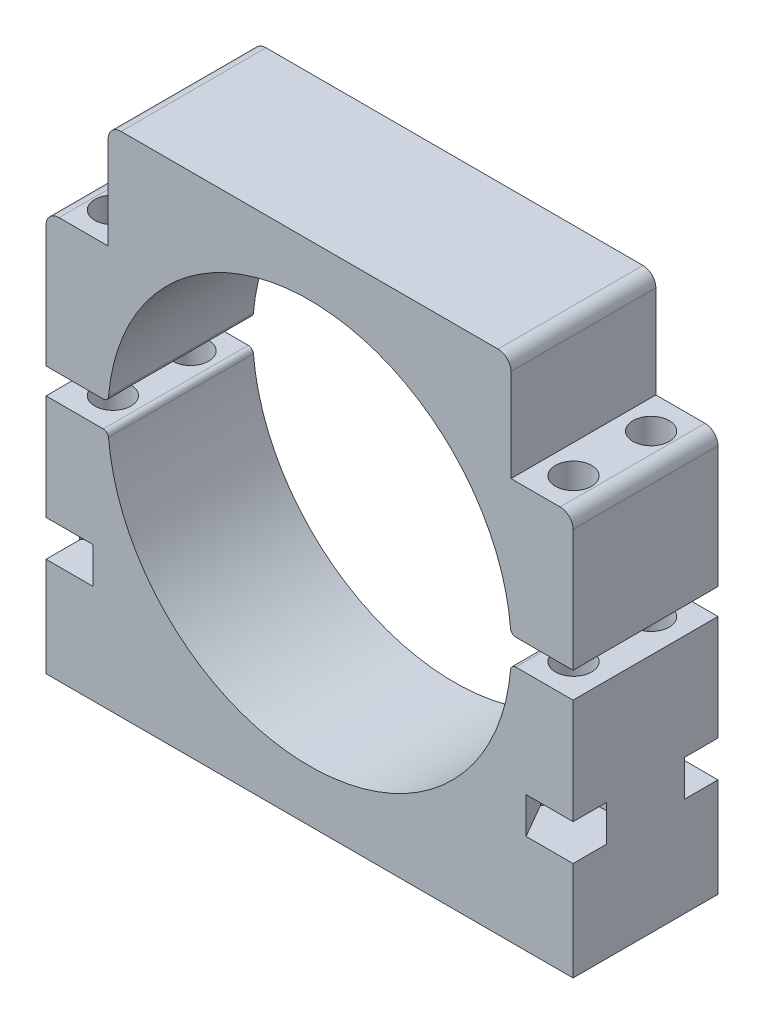
from build123d import *

# Parameters (mm, degrees)
BOSS_EXTRUDE1_DEPTH     = 28
BOSS_EXTRUDE2_DEPTH     = 28
SKETCH3_R               = 3.5
CUT_EXTRUDE1_DEPTH      = 58.42
FILLET1_R               = 1
FILLET2_R               = 1
SKETCH5_W               = 12
SKETCH5_H               = 20.425
CUT_EXTRUDE3_DEPTH      = 29
CUT_EXTRUDE3_DEPTH_BACK = 1
FILLET3_R               = 2.5
CUT_EXTRUDE4_DEPTH      = 7


with BuildPart() as part:
    # Sketch1 → Boss-Extrude1 (new body)
    with BuildSketch(Plane.XY):
        with BuildLine():
            Line((-38.919789311, -2.5), (-50.919789311, -2.5))
            Line((-50.919789311, -2.5), (-50.919789311, -49))
            Line((-50.919789311, -49), (50.919789311, -49))
            Line((50.919789311, -49), (50.919789311, -2.5))
            Line((50.919789311, -2.5), (38.919789311, -2.5))
            ThreePointArc((38.919789311, -2.5), (0, -39), (-38.919789311, -2.5))
        make_face()
    extrude(amount=BOSS_EXTRUDE1_DEPTH)


with BuildPart() as body_2:
    # Sketch2 → Boss-Extrude2 (new body)
    with BuildSketch(Plane.XY):
        with BuildLine():
            Line((-38.919789311, 2.5), (-50.919789311, 2.5))
            Line((-50.919789311, 2.5), (-50.919789311, 49))
            Line((-50.919789311, 49), (50.919789311, 49))
            Line((50.919789311, 49), (50.919789311, 2.5))
            Line((50.919789311, 2.5), (38.919789311, 2.5))
            ThreePointArc((38.919789311, 2.5), (0, 39), (-38.919789311, 2.5))
        make_face()
    extrude(amount=BOSS_EXTRUDE2_DEPTH)


with BuildPart() as cut_extrude1_tool:
    # Sketch3 → Cut-Extrude1 (new body)
    with BuildSketch(Plane(origin=(0, 28.575, 0), x_dir=(1, 0, 0), z_dir=(0, 1, 0))):
        with Locations((-44.503984444, -6.5)):
            Circle(SKETCH3_R)
        with Locations((-44.503984444, -21.5)):
            Circle(SKETCH3_R)
    cut_extrude1 = extrude(amount=-CUT_EXTRUDE1_DEPTH)


with BuildPart() as part_1:
    add(part.part)

    # Cut-Extrude1: cut by cut_extrude1_tool
    add(cut_extrude1_tool.part, mode=Mode.SUBTRACT)

    # Fillet1
    fillet1_edges = [part_1.edges().sort_by_distance(p)[0] for p in [
        (38.919789311, -2.5, 14),
        (-38.919789311, -2.5, 14),
    ]]
    fillet(fillet1_edges, radius=FILLET1_R)

    # Sketch7 → Cut-Extrude4 (cut)
    with BuildSketch(Plane(origin=(0, -29.845, 0), x_dir=(1, 0, 0), z_dir=(0, 1, 0))):
        Polygon((-38.088179578, -6.5), (-41.296082011, -0.94375), (-41.840956328, 0), (-50.919789311, 0), (-50.919789311, -6.5), (-47.711886878, -12.05625), (-41.296082011, -12.05625), align=None)
        Polygon((-50.919789311, -28), (-41.840956328, -28), (-41.296082011, -27.05625), (-38.088179578, -21.5), (-41.296082011, -15.94375), (-47.711886878, -15.94375), (-50.919789311, -21.5), align=None)
    cut_extrude4 = extrude(amount=CUT_EXTRUDE4_DEPTH, mode=Mode.SUBTRACT)


with BuildPart() as body_2_1:
    add(body_2.part)

    # Cut-Extrude1: cut by cut_extrude1_tool
    add(cut_extrude1_tool.part, mode=Mode.SUBTRACT)

    # Fillet2
    fillet2_edges = [body_2_1.edges().sort_by_distance(p)[0] for p in [
        (-38.919789311, 2.5, 14),
        (38.919789311, 2.5, 14),
    ]]
    fillet(fillet2_edges, radius=FILLET2_R)

    # Sketch5 → Cut-Extrude3 (cut, two sides)
    with BuildSketch(Plane.XY) as cut_extrude3_sk:
        with Locations((-44.919789311, 38.7875)):
            Rectangle(SKETCH5_W, SKETCH5_H)
        with Locations((44.919789311, 38.7875)):
            Rectangle(SKETCH5_W, SKETCH5_H)
    extrude(amount=CUT_EXTRUDE3_DEPTH, mode=Mode.SUBTRACT)
    extrude(cut_extrude3_sk.sketch, amount=-CUT_EXTRUDE3_DEPTH_BACK, mode=Mode.SUBTRACT)

    # Fillet3
    fillet3_edges = [body_2_1.edges().sort_by_distance(p)[0] for p in [
        (-50.919789311, 28.575, 14),
        (-38.919789311, 49, 14),
        (38.919789311, 49, 14),
        (50.919789311, 28.575, 14),
    ]]
    fillet(fillet3_edges, radius=FILLET3_R)


with BuildPart() as mirror3_tool:
    # Mirror3: Cut-Extrude1, Cut-Extrude4 across plane
    add(cut_extrude1.mirror(Plane(origin=(0, 0, 0), x_dir=(0, 0, 1), z_dir=(1, 0, 0))))
    add(cut_extrude4.mirror(Plane(origin=(0, 0, 0), x_dir=(0, 0, 1), z_dir=(1, 0, 0))))


with BuildPart() as part_2:
    add(part_1.part)

    # Mirror3: cut by mirror3_tool
    add(mirror3_tool.part, mode=Mode.SUBTRACT)


with BuildPart() as body_2_2:
    add(body_2_1.part)

    # Mirror3: cut by mirror3_tool
    add(mirror3_tool.part, mode=Mode.SUBTRACT)


solid = Compound([part_2.part, body_2_2.part])
